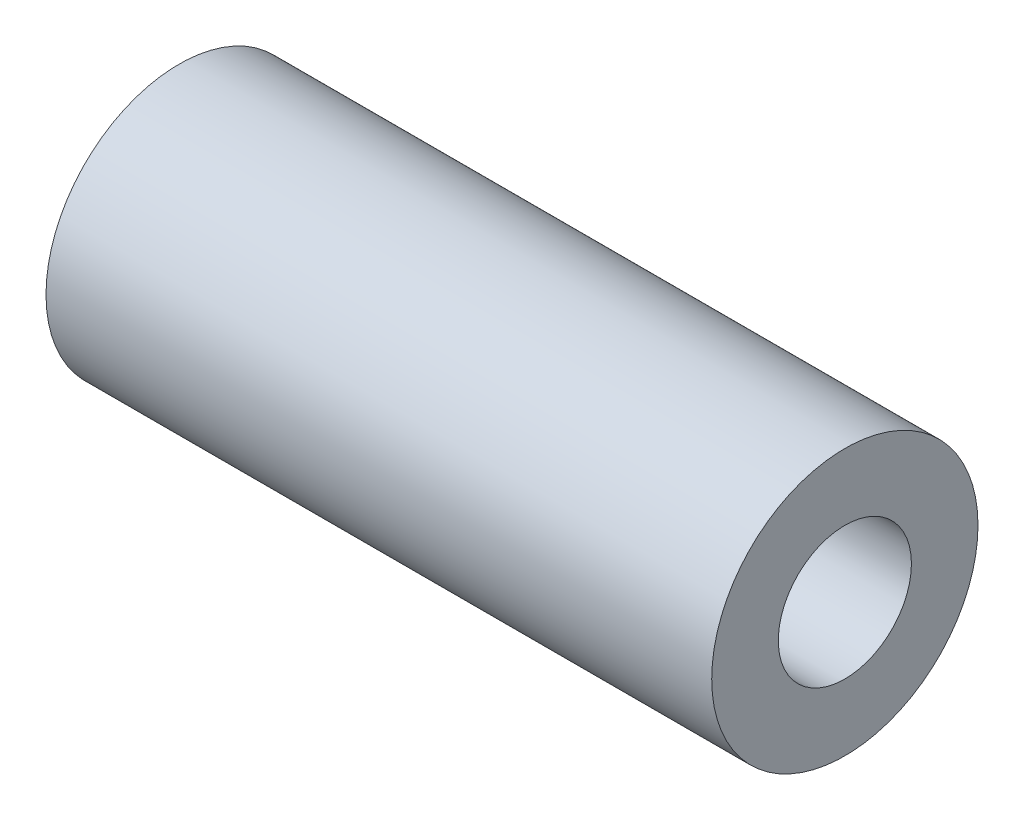
from build123d import *

# Parameters (mm, degrees)
SKETCH1_R           = 25.4
SKETCH1_R_2         = 12.7
BOSS_EXTRUDE1_DEPTH = 63.5


with BuildPart() as part:
    # Sketch1 → Boss-Extrude1 (new body, symmetric)
    with BuildSketch(Plane(origin=(0, 0, 0), x_dir=(0, 0, -1), z_dir=(1, 0, 0))):
        Circle(SKETCH1_R)
        Circle(SKETCH1_R_2, mode=Mode.SUBTRACT)
    extrude(amount=BOSS_EXTRUDE1_DEPTH, both=True)


solid = part.part
